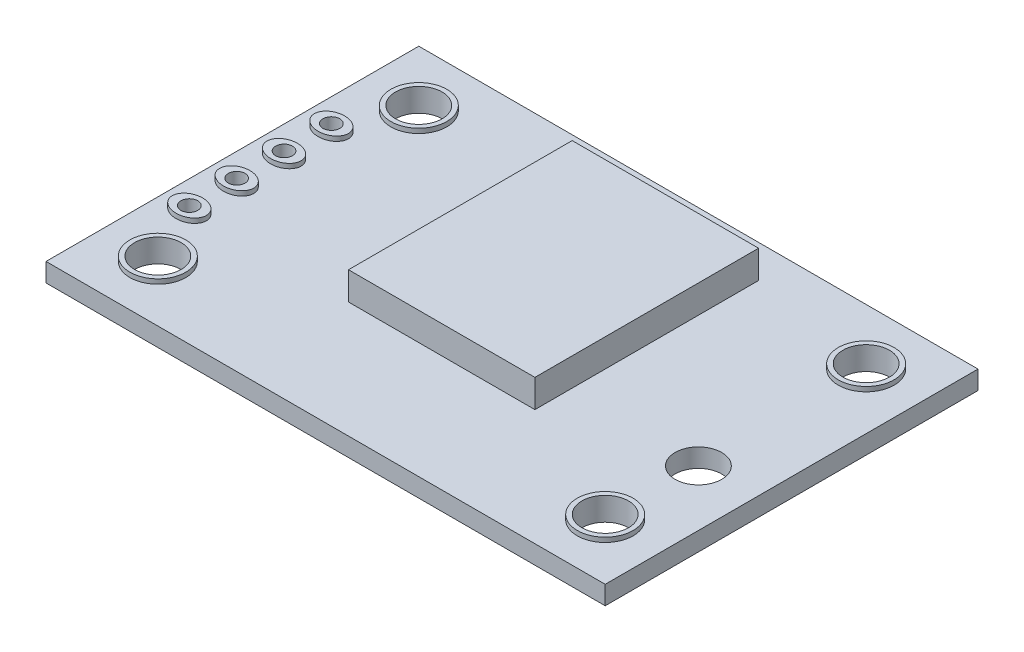
from build123d import *

# Parameters (mm, degrees)
SKETCH1_W               = 30
SKETCH1_H               = 20
SKETCH1_R               = 1.25
BOSS_EXTRUDE1_DEPTH     = 1
SKETCH2_W               = 10
SKETCH2_H               = 12
BOSS_EXTRUDE2_DEPTH     = 2.5
SKETCH3_R               = 1.5
SKETCH3_R_2             = 1.25
SKETCH3_RX              = 0.916848001
SKETCH3_RY              = 0.710785017
SKETCH3_R_3             = 0.45
BOSS_EXTRUDE3_DEPTH     = 0.25
SKETCH4_R               = 0.45
CUT_EXTRUDE1_DEPTH      = 3.5
CUT_EXTRUDE1_DEPTH_BACK = 5


with BuildPart() as part:
    # Sketch1 → Boss-Extrude1 (new body)
    with BuildSketch(Plane(origin=(0, 0, 0), x_dir=(1, 0, 0), z_dir=(0, 1, 0))):
        Rectangle(SKETCH1_W, SKETCH1_H)
        with Locations((-12, 7)):
            Circle(SKETCH1_R, mode=Mode.SUBTRACT)
        with Locations((12, 7)):
            Circle(SKETCH1_R, mode=Mode.SUBTRACT)
        with Locations((12, -7)):
            Circle(SKETCH1_R, mode=Mode.SUBTRACT)
        with Locations((-12, -7)):
            Circle(SKETCH1_R, mode=Mode.SUBTRACT)
        with Locations((12, -2)):
            Circle(SKETCH1_R, mode=Mode.SUBTRACT)
    extrude(amount=BOSS_EXTRUDE1_DEPTH)

    # Sketch2 → Boss-Extrude2 (add)
    with BuildSketch(Plane(origin=(0, 0, 0), x_dir=(1, 0, 0), z_dir=(0, 1, 0))):
        with Locations((0, 2.22835765)):
            Rectangle(SKETCH2_W, SKETCH2_H)
    extrude(amount=BOSS_EXTRUDE2_DEPTH)

    # Sketch3 → Boss-Extrude3 (add)
    with BuildSketch(Plane(origin=(0, 1, 0), x_dir=(1, 0, 0), z_dir=(0, 1, 0))):
        with Locations((-12, 7)):
            Circle(SKETCH3_R)
        with Locations((-12, 7)):
            Circle(SKETCH3_R_2, mode=Mode.SUBTRACT)
        with Locations((12, 7)):
            Circle(SKETCH3_R)
        with Locations((12, 7)):
            Circle(SKETCH3_R_2, mode=Mode.SUBTRACT)
        with Locations((12, -7)):
            Circle(SKETCH3_R)
        with Locations((12, -7)):
            Circle(SKETCH3_R_2, mode=Mode.SUBTRACT)
        with Locations((-12, -7)):
            Circle(SKETCH3_R)
        with Locations((-12, -7)):
            Circle(SKETCH3_R_2, mode=Mode.SUBTRACT)
        with Locations((-13.5, 3.81)):
            Ellipse(SKETCH3_RX, SKETCH3_RY)
        with Locations((-13.5, 3.81)):
            Circle(SKETCH3_R_3, mode=Mode.SUBTRACT)
        with Locations((-13.5, 1.27)):
            Ellipse(SKETCH3_RX, SKETCH3_RY)
        with Locations((-13.5, 1.27)):
            Circle(SKETCH3_R_3, mode=Mode.SUBTRACT)
        with Locations((-13.5, -1.27)):
            Ellipse(SKETCH3_RX, SKETCH3_RY)
        with Locations((-13.5, -1.27)):
            Circle(SKETCH3_R_3, mode=Mode.SUBTRACT)
        with Locations((-13.5, -3.81)):
            Ellipse(SKETCH3_RX, SKETCH3_RY)
        with Locations((-13.5, -3.81)):
            Circle(SKETCH3_R_3, mode=Mode.SUBTRACT)
    extrude(amount=BOSS_EXTRUDE3_DEPTH)

    # Sketch4 → Cut-Extrude1 (cut, two sides)
    with BuildSketch(Plane(origin=(0, 0, 0), x_dir=(1, 0, 0), z_dir=(0, 1, 0))) as cut_extrude1_sk:
        with Locations((-13.5, 3.81)):
            Circle(SKETCH4_R)
        with Locations((-13.5, 1.27)):
            Circle(SKETCH4_R)
        with Locations((-13.5, -1.27)):
            Circle(SKETCH4_R)
        with Locations((-13.5, -3.81)):
            Circle(SKETCH4_R)
    extrude(amount=CUT_EXTRUDE1_DEPTH, mode=Mode.SUBTRACT)
    extrude(cut_extrude1_sk.sketch, amount=-CUT_EXTRUDE1_DEPTH_BACK, mode=Mode.SUBTRACT)


solid = part.part
